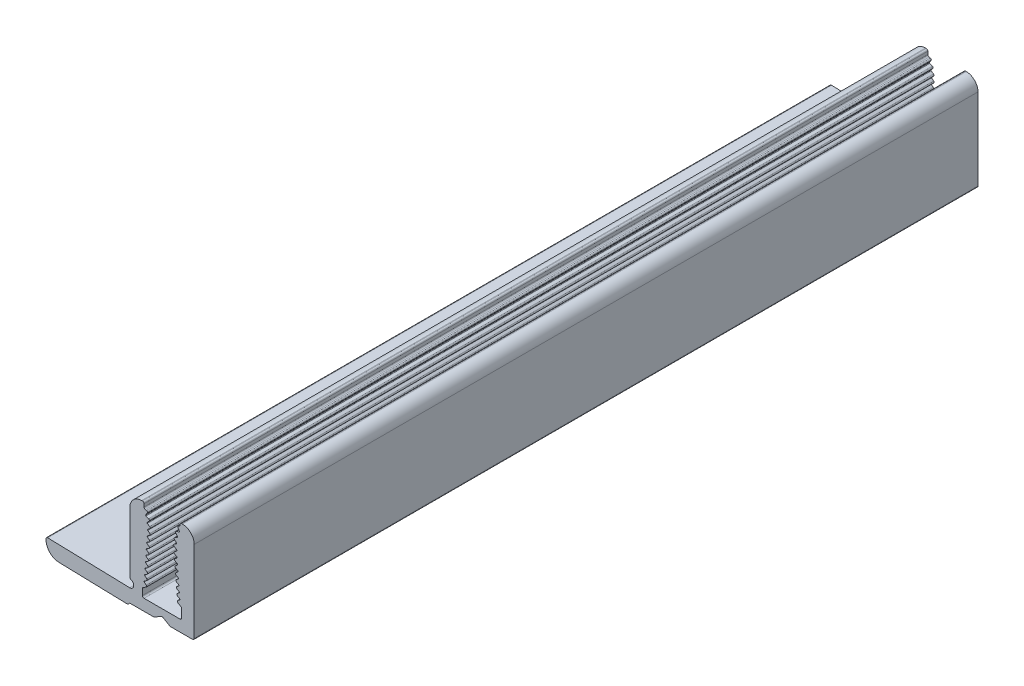
from build123d import *

# Parameters (mm, degrees)
EXTRUDE_1_DEPTH = 100


with BuildPart() as part:
    # Эскиз1 → Бобышка-Вытянуть1 (new body)
    with BuildSketch(Plane.XY):
        with BuildLine():
            Line((311.090891371, 325.050300163), (319.788031344, 324.810224137))
            ThreePointArc((319.788031344, 324.810224137), (319.867529895, 324.824333608), (319.934971402, 324.868726626))
            Line((319.934971402, 324.868726626), (320.131212385, 325.064967609))
            Line((320.131212385, 325.064967609), (323.201898914, 325.064967609))
            Line((323.201898914, 325.064967609), (324.141129398, 325.607232582))
            ThreePointArc((324.141129398, 325.607232582), (324.241129398, 325.634027502), (324.341129398, 325.607232582))
            Line((324.341129398, 325.607232582), (325.280359883, 325.064967609))
            Line((325.280359883, 325.064967609), (328.141129398, 325.064967609))
            ThreePointArc((328.141129398, 325.064967609), (328.282550755, 325.123546253), (328.341129398, 325.264967609))
            Line((328.341129398, 325.264967609), (328.341129398, 335.660147982))
            ThreePointArc((328.341129398, 335.660147982), (327.90178957, 336.720808154), (326.841129398, 337.160147982))
            Line((326.841129398, 337.160147982), (326.751018387, 337.160147982))
            ThreePointArc((326.751018387, 337.160147982), (326.609597031, 337.101569338), (326.551018387, 336.960147982))
            Line((326.551018387, 336.960147982), (326.551018387, 336.898541414))
            ThreePointArc((326.551018387, 336.898541414), (326.50335276, 336.768948826), (326.383075998, 336.701127358))
            ThreePointArc((326.383075998, 336.701127358), (326.273318939, 336.619532133), (326.27674616, 336.482811079))
            Line((326.27674616, 336.482811079), (326.447277251, 336.173129229))
            ThreePointArc((326.447277251, 336.173129229), (326.451076485, 336.109455402), (326.40409571, 336.066309172))
            Line((326.40409571, 336.066309172), (326.066600192, 335.962234792))
            ThreePointArc((326.066600192, 335.962234792), (325.96870237, 335.864988428), (325.99301838, 335.729159231))
            Line((325.99301838, 335.729159231), (326.209580677, 335.450169137))
            ThreePointArc((326.209580677, 335.450169137), (326.223272021, 335.387868756), (326.183601656, 335.337918255))
            Line((326.183601656, 335.337918255), (325.866171063, 335.182285611))
            ThreePointArc((325.866171063, 335.182285611), (325.784195666, 335.067661744), (325.834812154, 334.936145328))
            Line((325.834812154, 334.936145328), (326.08754177, 334.719229546))
            ThreePointArc((326.08754177, 334.719229546), (326.113257599, 334.657577201), (326.079055863, 334.600196396))
            Line((326.079055863, 334.600196396), (325.798110573, 334.421326447))
            ThreePointArc((325.798110573, 334.421326447), (325.729347274, 334.298199433), (325.794435238, 334.173090641))
            Line((325.794435238, 334.173090641), (326.083482656, 333.976799787))
            ThreePointArc((326.083482656, 333.976799787), (326.132220057, 333.889114864), (326.090713273, 333.797784875))
            Line((326.090713273, 333.797784875), (325.834605364, 333.591823003))
            ThreePointArc((325.834605364, 333.591823003), (325.779589072, 333.464527861), (325.853621615, 333.347267346))
            Line((325.853621615, 333.347267346), (326.141686948, 333.18153099))
            ThreePointArc((326.141686948, 333.18153099), (326.178703219, 333.122900733), (326.151195073, 333.059253162))
            Line((326.151195073, 333.059253162), (325.892212173, 332.850979224))
            ThreePointArc((325.892212173, 332.850979224), (325.837195882, 332.723684082), (325.911228424, 332.606423567))
            Line((325.911228424, 332.606423567), (326.199293757, 332.440687211))
            ThreePointArc((326.199293757, 332.440687211), (326.236310028, 332.382056954), (326.208801882, 332.318409383))
            Line((326.208801882, 332.318409383), (325.949818982, 332.110135445))
            ThreePointArc((325.949818982, 332.110135445), (325.894802691, 331.982840302), (325.968835233, 331.865579788))
            Line((325.968835233, 331.865579788), (326.256900566, 331.699843432))
            ThreePointArc((326.256900566, 331.699843432), (326.293916837, 331.641213174), (326.266408691, 331.577565603))
            Line((326.266408691, 331.577565603), (326.007425791, 331.369291665))
            ThreePointArc((326.007425791, 331.369291665), (325.9524095, 331.241996523), (326.026442042, 331.124736008))
            Line((326.026442042, 331.124736008), (326.314507375, 330.958999652))
            ThreePointArc((326.314507375, 330.958999652), (326.351523646, 330.900369395), (326.3240155, 330.836721824))
            Line((326.3240155, 330.836721824), (326.0650326, 330.628447886))
            ThreePointArc((326.0650326, 330.628447886), (326.010016309, 330.501152743), (326.084048851, 330.383892229))
            Line((326.084048851, 330.383892229), (326.372114184, 330.218155873))
            ThreePointArc((326.372114184, 330.218155873), (326.409130455, 330.159525616), (326.381622309, 330.095878044))
            Line((326.381622309, 330.095878044), (326.12263941, 329.887604106))
            ThreePointArc((326.12263941, 329.887604106), (326.067623118, 329.760308964), (326.14165566, 329.643048449))
            Line((326.14165566, 329.643048449), (326.429720993, 329.477312094))
            ThreePointArc((326.429720993, 329.477312094), (326.466737264, 329.418681836), (326.439229119, 329.355034265))
            Line((326.439229119, 329.355034265), (326.180246219, 329.146760327))
            ThreePointArc((326.180246219, 329.146760327), (326.125229927, 329.019465185), (326.199262469, 328.90220467))
            Line((326.199262469, 328.90220467), (326.487327802, 328.736468314))
            ThreePointArc((326.487327802, 328.736468314), (326.524344073, 328.677838057), (326.496835928, 328.614190486))
            Line((326.496835928, 328.614190486), (326.237853028, 328.405916548))
            ThreePointArc((326.237853028, 328.405916548), (326.182836736, 328.278621405), (326.256869279, 328.161360891))
            Line((326.256869279, 328.161360891), (326.640868299, 327.940429765))
            ThreePointArc((326.640868299, 327.940429765), (326.71425909, 327.867204665), (326.741129398, 327.767074201))
            Line((326.741129398, 327.767074201), (326.741129398, 326.710147982))
            ThreePointArc((326.741129398, 326.710147982), (326.682550755, 326.568726626), (326.541129398, 326.510147982))
            Line((326.541129398, 326.510147982), (321.941129398, 326.510147982))
            ThreePointArc((321.941129398, 326.510147982), (321.799708042, 326.568726626), (321.741129398, 326.710147982))
            Line((321.741129398, 326.710147982), (321.741129398, 327.486517476))
            ThreePointArc((321.741129398, 327.486517476), (321.767999707, 327.586647941), (321.841390498, 327.659873041))
            Line((321.841390498, 327.659873041), (322.202552193, 327.867664872))
            ThreePointArc((322.202552193, 327.867664872), (322.276584735, 327.984925387), (322.221568443, 328.112220529))
            Line((322.221568443, 328.112220529), (321.962585543, 328.320494467))
            ThreePointArc((321.962585543, 328.320494467), (321.935077398, 328.384142038), (321.972093669, 328.442772296))
            Line((321.972093669, 328.442772296), (322.260159002, 328.608508652))
            ThreePointArc((322.260159002, 328.608508652), (322.334191544, 328.725769166), (322.279175253, 328.853064309))
            Line((322.279175253, 328.853064309), (322.020192353, 329.061338247))
            ThreePointArc((322.020192353, 329.061338247), (321.992684207, 329.124985818), (322.029700478, 329.183616075))
            Line((322.029700478, 329.183616075), (322.317765811, 329.349352431))
            ThreePointArc((322.317765811, 329.349352431), (322.391798353, 329.466612946), (322.336782062, 329.593908088))
            Line((322.336782062, 329.593908088), (322.077799162, 329.802182026))
            ThreePointArc((322.077799162, 329.802182026), (322.050291016, 329.865829597), (322.087307287, 329.924459854))
            Line((322.087307287, 329.924459854), (322.37537262, 330.09019621))
            ThreePointArc((322.37537262, 330.09019621), (322.449405162, 330.207456725), (322.394388871, 330.334751867))
            Line((322.394388871, 330.334751867), (322.135405971, 330.543025805))
            ThreePointArc((322.135405971, 330.543025805), (322.107897825, 330.606673377), (322.144914096, 330.665303634))
            Line((322.144914096, 330.665303634), (322.432979429, 330.83103999))
            ThreePointArc((322.432979429, 330.83103999), (322.507011971, 330.948300504), (322.45199568, 331.075595647))
            Line((322.45199568, 331.075595647), (322.19301278, 331.283869585))
            ThreePointArc((322.19301278, 331.283869585), (322.165504634, 331.347517156), (322.202520905, 331.406147413))
            Line((322.202520905, 331.406147413), (322.490586238, 331.571883769))
            ThreePointArc((322.490586238, 331.571883769), (322.564618781, 331.689144284), (322.509602489, 331.816439426))
            Line((322.509602489, 331.816439426), (322.250619589, 332.024713364))
            ThreePointArc((322.250619589, 332.024713364), (322.223111443, 332.088360935), (322.260127715, 332.146991193))
            Line((322.260127715, 332.146991193), (322.548193048, 332.312727548))
            ThreePointArc((322.548193048, 332.312727548), (322.62222559, 332.429988063), (322.567209298, 332.557283205))
            Line((322.567209298, 332.557283205), (322.308226398, 332.765557144))
            ThreePointArc((322.308226398, 332.765557144), (322.280718253, 332.829204715), (322.317734524, 332.887834972))
            Line((322.317734524, 332.887834972), (322.605799857, 333.053571328))
            ThreePointArc((322.605799857, 333.053571328), (322.679832399, 333.170831842), (322.624816107, 333.298126985))
            Line((322.624816107, 333.298126985), (322.365833207, 333.506400923))
            ThreePointArc((322.365833207, 333.506400923), (322.338325062, 333.570048494), (322.375341333, 333.628678751))
            Line((322.375341333, 333.628678751), (322.663406666, 333.794415107))
            ThreePointArc((322.663406666, 333.794415107), (322.737622, 333.914334818), (322.678209577, 334.042236409))
            Line((322.678209577, 334.042236409), (322.411350306, 334.241512209))
            ThreePointArc((322.411350306, 334.241512209), (322.381512328, 334.301278508), (322.411743655, 334.360846808))
            Line((322.411743655, 334.360846808), (322.679910814, 334.558359061))
            ThreePointArc((322.679910814, 334.558359061), (322.740171486, 334.685745276), (322.666950969, 334.806150228))
            Line((322.666950969, 334.806150228), (322.361978717, 334.984967527))
            ThreePointArc((322.361978717, 334.984967527), (322.326134471, 335.037730965), (322.344422849, 335.098840094))
            Line((322.344422849, 335.098840094), (322.581141078, 335.36094538))
            ThreePointArc((322.581141078, 335.36094538), (322.615495018, 335.494589107), (322.525103363, 335.598849299))
            Line((322.525103363, 335.598849299), (322.196285999, 335.727743993))
            ThreePointArc((322.196285999, 335.727743993), (322.152645383, 335.774265892), (322.161171245, 335.837480605))
            Line((322.161171245, 335.837480605), (322.354269218, 336.133617186))
            ThreePointArc((322.354269218, 336.133617186), (322.366051346, 336.274044313), (322.25526952, 336.361141866))
            Line((322.25526952, 336.361141866), (322.106867151, 336.386946327))
            ThreePointArc((322.106867151, 336.386946327), (321.988073119, 336.455250544), (321.941129398, 336.58398972))
            Line((321.941129398, 336.58398972), (321.941129398, 336.960147982))
            ThreePointArc((321.941129398, 336.960147982), (321.882550755, 337.101569338), (321.741129398, 337.160147982))
            Line((321.741129398, 337.160147982), (321.641129398, 337.160147982))
            ThreePointArc((321.641129398, 337.160147982), (320.580469227, 336.720808154), (320.141129398, 335.660147982))
            Line((320.141129398, 335.660147982), (320.141129398, 327.928017713))
            ThreePointArc((320.141129398, 327.928017713), (320.179892433, 327.809684958), (320.281155808, 327.737221569))
            ThreePointArc((320.281155808, 327.737221569), (320.624342386, 327.177574585), (320.117425076, 326.760421597))
            Line((320.117425076, 326.760421597), (309.643319038, 327.04954903))
            ThreePointArc((309.643319038, 327.04954903), (309.498343785, 326.992984419), (309.437800337, 326.849625185))
            Line((309.437800337, 326.849625185), (309.437800337, 326.749652848))
            ThreePointArc((309.437800337, 326.749652848), (309.919246841, 325.564272159), (311.090891371, 325.050300163))
        make_face()
    extrude(amount=EXTRUDE_1_DEPTH)


solid = part.part
